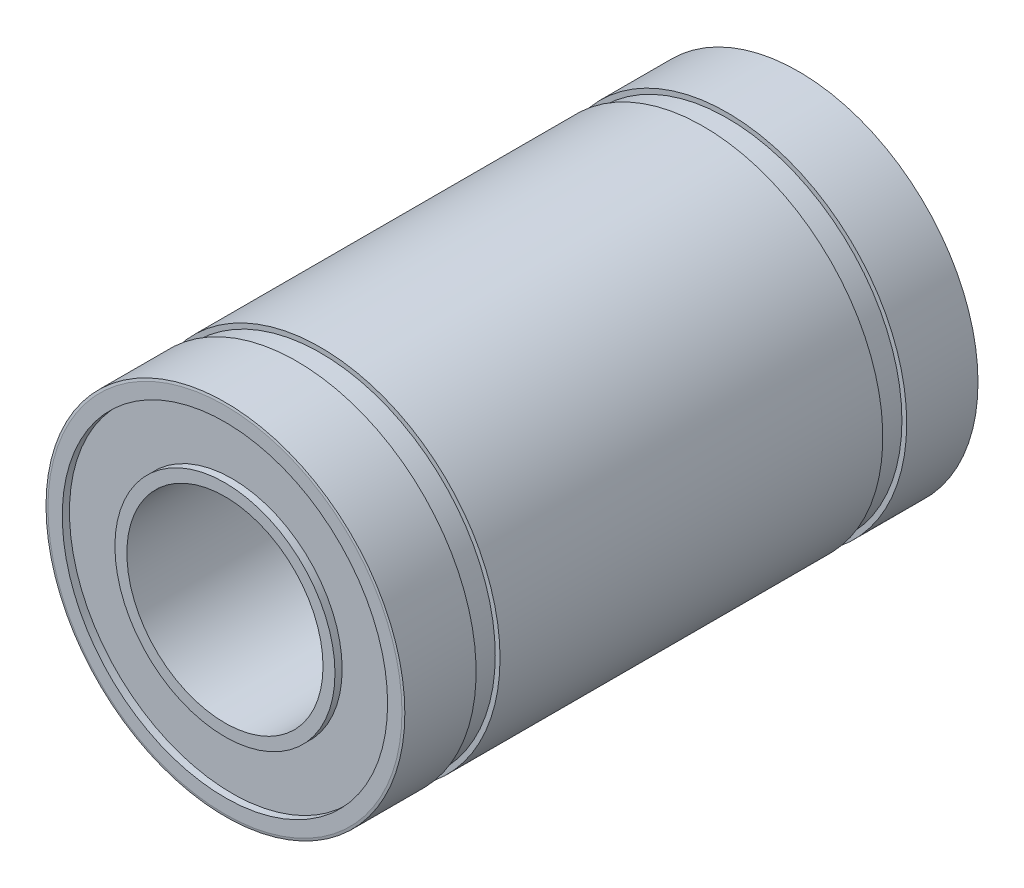
from build123d import *

# Parameters (mm, degrees)
CROQUIS1_R              = 7.5
CROQUIS1_R_2            = 4.1
SALIENTE_EXTRUIR1_DEPTH = 24
CROQUIS2_W              = 0.4
CROQUIS2_H              = 1


with BuildPart() as part:
    # Croquis1 → Saliente-Extruir1 (new body)
    with BuildSketch(Plane.XY):
        Circle(CROQUIS1_R)
        Circle(CROQUIS1_R_2, mode=Mode.SUBTRACT)
    extrude(amount=SALIENTE_EXTRUIR1_DEPTH)

    # Croquis2 → Cortar-Revolución1 (revolve, cut)
    with BuildSketch(Plane(origin=(0, 0, 0), x_dir=(1, 0, 0), z_dir=(0, 1, 0))):
        Polygon((-7.5, -0.02), (-7.4, 0), (-6.8, 0), (-6.8, -0.3), (-4.6, -0.3), (-4.6, 0), (-4.1, 0), (-4.1, 0.7), (-7.5, 0.7), align=None)
        Polygon((-7.5, -24.7), (-7.5, -23.98), (-7.4, -24), (-6.8, -24), (-6.8, -23.7), (-4.6, -23.7), (-4.6, -24), (-4.1, -24), (-4.1, -24.7), align=None)
        with Locations((-7.5, -3.5)):
            Rectangle(CROQUIS2_W, CROQUIS2_H)
        with Locations((-7.5, -20.5)):
            Rectangle(CROQUIS2_W, CROQUIS2_H)
    revolve(axis=Axis((0, 0, 24), (0, 0, -1)), mode=Mode.SUBTRACT)


solid = part.part
